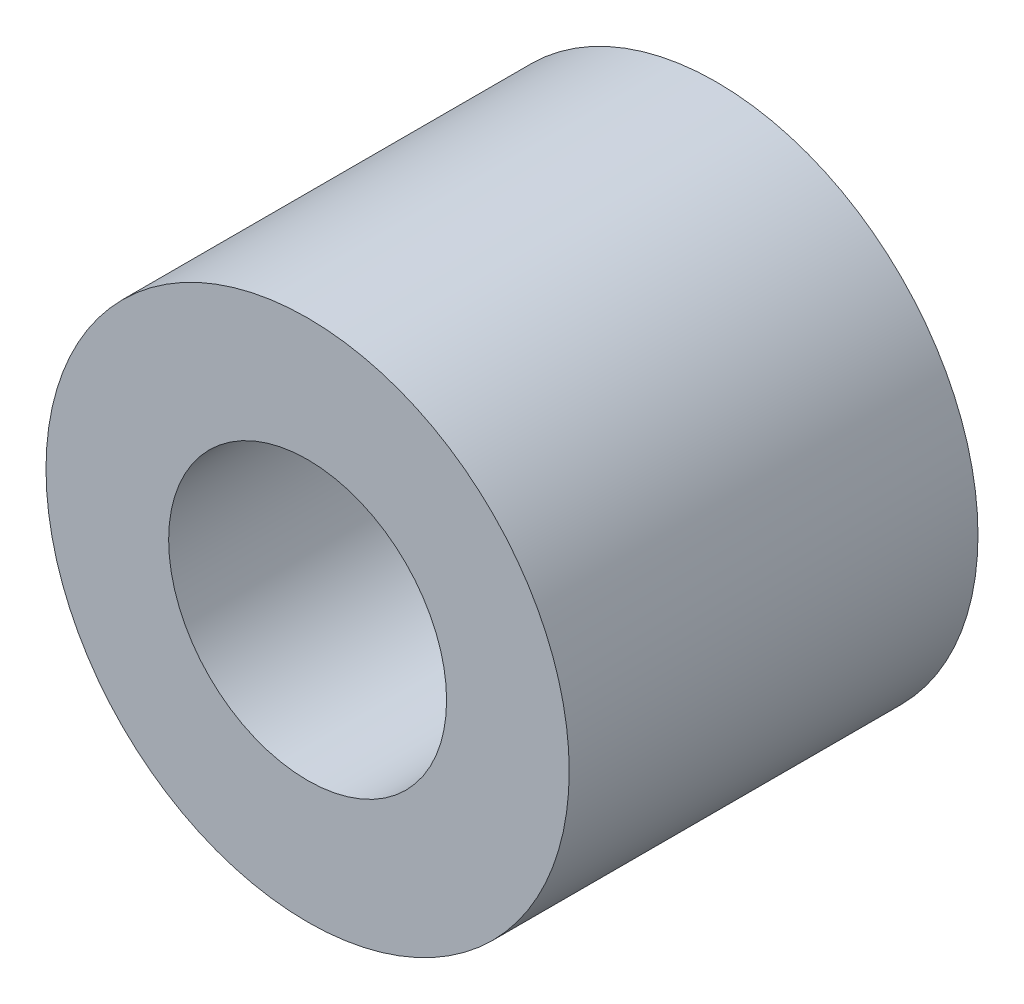
from build123d import *

# Parameters (mm, degrees)
ESQUISSE1_R        = 3.2
ESQUISSE1_R_2      = 1.7
BOSS_EXTRU_1_DEPTH = 5


with BuildPart() as part:
    # Esquisse1 → Boss.-Extru.1 (new body)
    with BuildSketch(Plane.XY):
        with Locations((-30.301926647, 53.599979038)):
            Circle(ESQUISSE1_R)
        with Locations((-30.301926647, 53.599979038)):
            Circle(ESQUISSE1_R_2, mode=Mode.SUBTRACT)
    extrude(amount=BOSS_EXTRU_1_DEPTH)


solid = part.part
